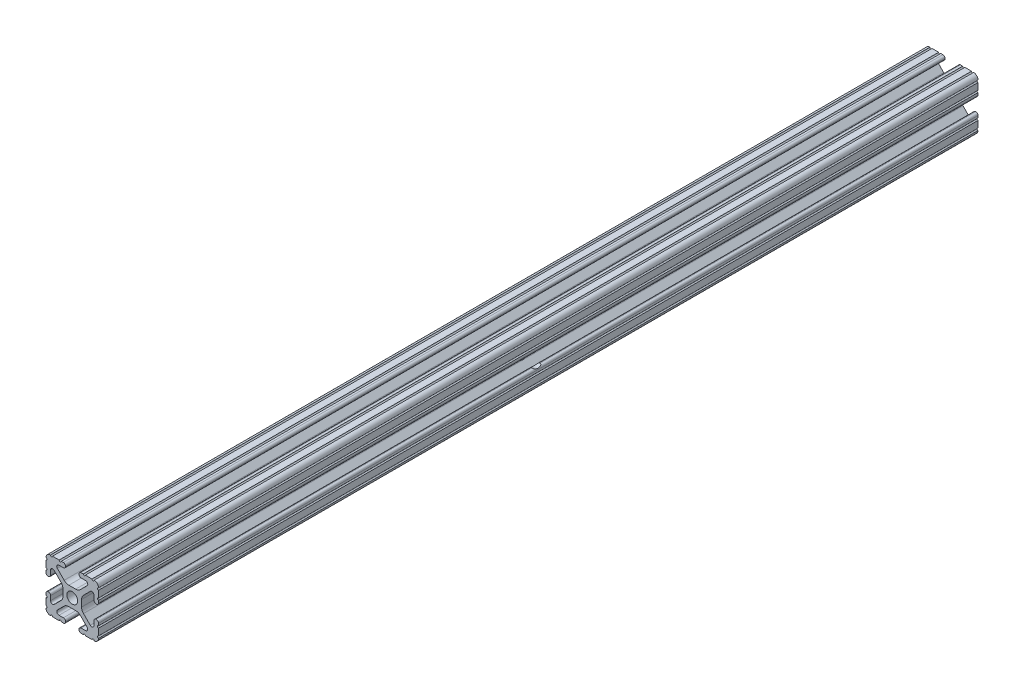
from build123d import *

# Parameters (mm, degrees)
SKETCH1_R           = 2.6035
BOSS_EXTRUDE1_DEPTH = 212.725
SKETCH2_R           = 3.81
CUT_EXTRUDE1_DEPTH  = 25.4


with BuildPart() as part:
    # Sketch1 → Boss-Extrude1 (new body, symmetric)
    with BuildSketch(Plane.XY):
        with BuildLine():
            Line((-7.179650497, -8.645192506), (-3.952270251, -5.423690499))
            ThreePointArc((-3.952270251, -5.423690499), (-2.922936451, -4.736929036), (-1.709253557, -4.4958))
            Line((-1.709253557, -4.4958), (1.709253557, -4.4958))
            ThreePointArc((1.709253557, -4.4958), (2.922936451, -4.736929036), (3.952270251, -5.423690499))
            Line((3.952270251, -5.423690499), (7.179650497, -8.645192506))
            ThreePointArc((7.179650497, -8.645192506), (7.41473083, -9.822813117), (6.416408329, -10.4902))
            Line((6.416408329, -10.4902), (4.287512407, -10.4902))
            ThreePointArc((4.287512407, -10.4902), (3.54574862, -10.79744862), (3.2385, -11.539212407))
            Line((3.2385, -11.539212407), (3.2385, -11.650987593))
            ThreePointArc((3.2385, -11.650987593), (3.54574862, -12.39275138), (4.287512407, -12.7))
            Line((4.287512407, -12.7), (5.317126718, -12.7))
            ThreePointArc((5.317126718, -12.7), (5.825126718, -12.192), (6.333126718, -12.7))
            Line((6.333126718, -12.7), (9.550443118, -12.7))
            ThreePointArc((9.550443118, -12.7), (10.058366869, -12.192000006), (10.566443095, -12.699847501))
            ThreePointArc((10.566443095, -12.699847501), (12.082537762, -12.08250727), (12.699846982, -10.566399977))
            ThreePointArc((12.699846982, -10.566399977), (12.192000006, -10.058323491), (12.7, -9.5504))
            Line((12.7, -9.5504), (12.7, -6.3330836))
            ThreePointArc((12.7, -6.3330836), (12.192, -5.8250836), (12.7, -5.3170836))
            Line((12.7, -5.3170836), (12.7, -4.287469289))
            ThreePointArc((12.7, -4.287469289), (12.39275138, -3.545705502), (11.650987593, -3.238456882))
            Line((11.650987593, -3.238456882), (11.539212407, -3.238456882))
            ThreePointArc((11.539212407, -3.238456882), (10.79744862, -3.545705502), (10.4902, -4.287469289))
            Line((10.4902, -4.287469289), (10.4902, -6.402089023))
            ThreePointArc((10.4902, -6.402089023), (9.856505071, -7.351067942), (8.737131347, -7.129408934))
            Line((8.737131347, -7.129408934), (5.441005833, -3.840816462))
            ThreePointArc((5.441005833, -3.840816462), (4.750877967, -2.809883091), (4.5085, -1.593185507))
            Line((4.5085, -1.593185507), (4.5085, 1.593185507))
            ThreePointArc((4.5085, 1.593185507), (4.750877967, 2.809883091), (5.441005833, 3.840816462))
            Line((5.441005833, 3.840816462), (8.737131347, 7.129408934))
            ThreePointArc((8.737131347, 7.129408934), (9.856505071, 7.351067942), (10.4902, 6.402089023))
            Line((10.4902, 6.402089023), (10.4902, 4.287469289))
            ThreePointArc((10.4902, 4.287469289), (10.79744862, 3.545705502), (11.539212407, 3.238456882))
            Line((11.539212407, 3.238456882), (11.650987593, 3.238456882))
            ThreePointArc((11.650987593, 3.238456882), (12.39275138, 3.545705502), (12.7, 4.287469289))
            Line((12.7, 4.287469289), (12.7, 5.3170836))
            ThreePointArc((12.7, 5.3170836), (12.192, 5.8250836), (12.7, 6.3330836))
            Line((12.7, 6.3330836), (12.7, 9.5504))
            ThreePointArc((12.7, 9.5504), (12.192000006, 10.058323491), (12.699846982, 10.566399977))
            ThreePointArc((12.699846982, 10.566399977), (12.082537762, 12.08250727), (10.566443095, 12.699847501))
            ThreePointArc((10.566443095, 12.699847501), (10.058366869, 12.192000006), (9.550443118, 12.7))
            Line((9.550443118, 12.7), (6.333126718, 12.7))
            ThreePointArc((6.333126718, 12.7), (5.825126718, 12.192), (5.317126718, 12.7))
            Line((5.317126718, 12.7), (4.287512407, 12.7))
            ThreePointArc((4.287512407, 12.7), (3.54574862, 12.39275138), (3.2385, 11.650987593))
            Line((3.2385, 11.650987593), (3.2385, 11.539212407))
            ThreePointArc((3.2385, 11.539212407), (3.54574862, 10.79744862), (4.287512407, 10.4902))
            Line((4.287512407, 10.4902), (6.476788598, 10.4902))
            ThreePointArc((6.476788598, 10.4902), (7.432222385, 9.85140422), (7.207036008, 8.724370562))
            Line((7.207036008, 8.724370562), (3.898272566, 5.423169045))
            ThreePointArc((3.898272566, 5.423169045), (2.869120213, 4.736787962), (1.655778399, 4.4958))
            Line((1.655778399, 4.4958), (-1.655778399, 4.4958))
            ThreePointArc((-1.655778399, 4.4958), (-2.869120213, 4.736787962), (-3.898272566, 5.423169045))
            Line((-3.898272566, 5.423169045), (-7.207036008, 8.724370562))
            ThreePointArc((-7.207036008, 8.724370562), (-7.432222385, 9.85140422), (-6.476788598, 10.4902))
            Line((-6.476788598, 10.4902), (-4.287512407, 10.4902))
            ThreePointArc((-4.287512407, 10.4902), (-3.54574862, 10.79744862), (-3.2385, 11.539212407))
            Line((-3.2385, 11.539212407), (-3.2385, 11.650987593))
            ThreePointArc((-3.2385, 11.650987593), (-3.54574862, 12.39275138), (-4.287512407, 12.7))
            Line((-4.287512407, 12.7), (-5.317126718, 12.7))
            ThreePointArc((-5.317126718, 12.7), (-5.825126718, 12.192), (-6.333126718, 12.7))
            Line((-6.333126718, 12.7), (-9.550443118, 12.7))
            ThreePointArc((-9.550443118, 12.7), (-10.058366869, 12.192000006), (-10.566443095, 12.699847501))
            ThreePointArc((-10.566443095, 12.699847501), (-12.082537762, 12.08250727), (-12.699846982, 10.566399977))
            ThreePointArc((-12.699846982, 10.566399977), (-12.192000006, 10.058323491), (-12.7, 9.5504))
            Line((-12.7, 9.5504), (-12.7, 6.3330836))
            ThreePointArc((-12.7, 6.3330836), (-12.192, 5.8250836), (-12.7, 5.3170836))
            Line((-12.7, 5.3170836), (-12.7, 4.287469289))
            ThreePointArc((-12.7, 4.287469289), (-12.39275138, 3.545705502), (-11.650987593, 3.238456882))
            Line((-11.650987593, 3.238456882), (-11.539212407, 3.238456882))
            ThreePointArc((-11.539212407, 3.238456882), (-10.79744862, 3.545705502), (-10.4902, 4.287469289))
            Line((-10.4902, 4.287469289), (-10.4902, 6.402089023))
            ThreePointArc((-10.4902, 6.402089023), (-9.856505071, 7.351067942), (-8.737131347, 7.129408934))
            Line((-8.737131347, 7.129408934), (-5.441005833, 3.840816462))
            ThreePointArc((-5.441005833, 3.840816462), (-4.750877967, 2.809883091), (-4.5085, 1.593185507))
            Line((-4.5085, 1.593185507), (-4.5085, -1.593185507))
            ThreePointArc((-4.5085, -1.593185507), (-4.750877967, -2.809883091), (-5.441005833, -3.840816462))
            Line((-5.441005833, -3.840816462), (-8.737131347, -7.129408934))
            ThreePointArc((-8.737131347, -7.129408934), (-9.856505071, -7.351067942), (-10.4902, -6.402089023))
            Line((-10.4902, -6.402089023), (-10.4902, -4.287469289))
            ThreePointArc((-10.4902, -4.287469289), (-10.79744862, -3.545705502), (-11.539212407, -3.238456882))
            Line((-11.539212407, -3.238456882), (-11.650987593, -3.238456882))
            ThreePointArc((-11.650987593, -3.238456882), (-12.39275138, -3.545705502), (-12.7, -4.287469289))
            Line((-12.7, -4.287469289), (-12.7, -5.3170836))
            ThreePointArc((-12.7, -5.3170836), (-12.192, -5.8250836), (-12.7, -6.3330836))
            Line((-12.7, -6.3330836), (-12.7, -9.5504))
            ThreePointArc((-12.7, -9.5504), (-12.192000006, -10.058323491), (-12.699846982, -10.566399977))
            ThreePointArc((-12.699846982, -10.566399977), (-12.082537762, -12.08250727), (-10.566443095, -12.699847501))
            ThreePointArc((-10.566443095, -12.699847501), (-10.058366869, -12.192000006), (-9.550443118, -12.7))
            Line((-9.550443118, -12.7), (-6.333126718, -12.7))
            ThreePointArc((-6.333126718, -12.7), (-5.825126718, -12.192), (-5.317126718, -12.7))
            Line((-5.317126718, -12.7), (-4.287512407, -12.7))
            ThreePointArc((-4.287512407, -12.7), (-3.54574862, -12.39275138), (-3.2385, -11.650987593))
            Line((-3.2385, -11.650987593), (-3.2385, -11.539212407))
            ThreePointArc((-3.2385, -11.539212407), (-3.54574862, -10.79744862), (-4.287512407, -10.4902))
            Line((-4.287512407, -10.4902), (-6.416408329, -10.4902))
            ThreePointArc((-6.416408329, -10.4902), (-7.41473083, -9.822813117), (-7.179650497, -8.645192506))
        make_face()
        Circle(SKETCH1_R, mode=Mode.SUBTRACT)
    extrude(amount=BOSS_EXTRUDE1_DEPTH, both=True)

    # Sketch2 → Cut-Extrude1 (cut)
    with BuildSketch(Plane.ZY.offset(12.7)):
        Circle(SKETCH2_R)
    extrude(amount=-CUT_EXTRUDE1_DEPTH, mode=Mode.SUBTRACT)


solid = part.part
